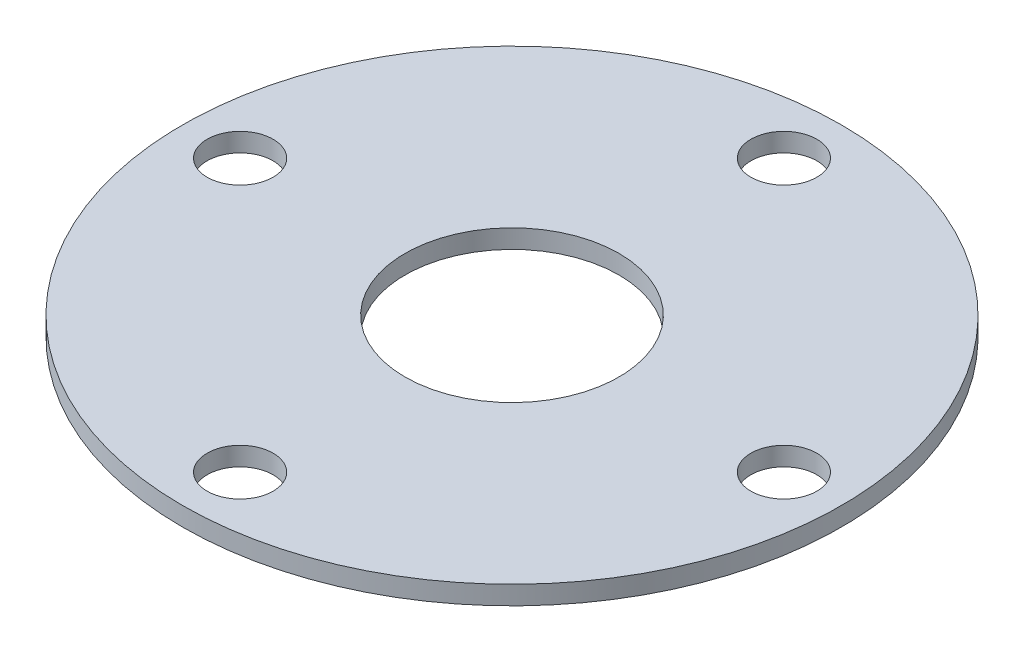
from build123d import *

# Parameters (mm, degrees)
SKETCH1_R           = 31.75
SKETCH1_R_2         = 10.3124
SKETCH1_R_3         = 3.175
BOSS_EXTRUDE1_DEPTH = 1.8034


with BuildPart() as part:
    # Sketch1 → Boss-Extrude1 (new body)
    with BuildSketch(Plane(origin=(0, 0, 0), x_dir=(1, 0, 0), z_dir=(0, 1, 0))):
        Circle(SKETCH1_R)
        Circle(SKETCH1_R_2, mode=Mode.SUBTRACT)
        with Locations((0, -26.19375)):
            Circle(SKETCH1_R_3, mode=Mode.SUBTRACT)
        with Locations((-26.19375, 0)):
            Circle(SKETCH1_R_3, mode=Mode.SUBTRACT)
        with Locations((0, 26.19375)):
            Circle(SKETCH1_R_3, mode=Mode.SUBTRACT)
        with Locations((26.19375, 0)):
            Circle(SKETCH1_R_3, mode=Mode.SUBTRACT)
    extrude(amount=BOSS_EXTRUDE1_DEPTH)


solid = part.part
